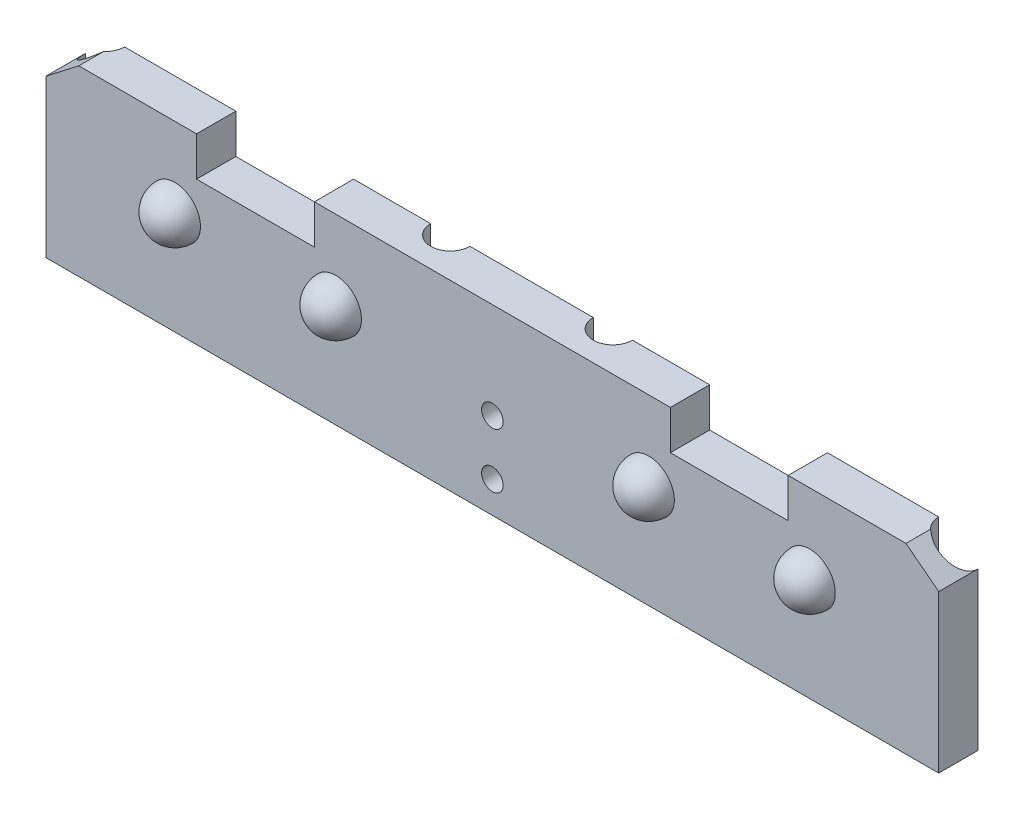
from build123d import *

# Parameters (mm, degrees)
SKETCH1_W                = 126.7
SKETCH1_H                = 14
BRACKETBASE_DEPTH        = 5
SKETCH2_R                = 1.375
MOUNTINGHOLES_DEPTH      = 1
MOUNTINGHOLES_DEPTH_BACK = 6
SKETCH5_W                = 126.7
SKETCH5_H                = 8.25
BASEEXTENSION_DEPTH      = 5
REVOLVE1_ANGLE           = 180
REVOLVE2_ANGLE           = 180
REVOLVE3_ANGLE           = 180
REVOLVE4_ANGLE           = 180
SKETCH9_W                = 15
SKETCH9_H                = 5
CUT_EXTRUDE2_DEPTH       = 4.25
CUT_EXTRUDE2_DEPTH_BACK  = 6
CUT_EXTRUDE3_DEPTH       = 4.25
CUT_EXTRUDE3_DEPTH_BACK  = 6
SKETCH11_R               = 2.5
CUT_EXTRUDE4_DEPTH       = 23.25
SKETCH12_R               = 2.5
CUT_EXTRUDE5_DEPTH       = 23.25
SKETCH13_W               = 6.5
SKETCH13_H               = 5
CUT_EXTRUDE6_DEPTH       = 1.0000001
CUT_EXTRUDE6_DEPTH_BACK  = 23.25
BOSS_EXTRUDE1_DEPTH      = 1


with BuildPart() as part:
    # Sketch1 → bracketBase (new body)
    with BuildSketch(Plane.XY):
        with Locations((63.35, 7)):
            Rectangle(SKETCH1_W, SKETCH1_H)
    extrude(amount=BRACKETBASE_DEPTH)

    # Sketch2 → mountingHoles (cut, two sides)
    with BuildSketch(Plane.XY.offset(5)) as mountingholes_sk:
        with Locations((63.35, 10)):
            Circle(SKETCH2_R)
        with Locations((63.35, 3)):
            Circle(SKETCH2_R)
        with Locations((123.7, 10)):
            Circle(SKETCH2_R)
        with Locations((123.7, 3)):
            Circle(SKETCH2_R)
        with Locations((3, 3)):
            Circle(SKETCH2_R)
        with Locations((3, 10)):
            Circle(SKETCH2_R)
    extrude(amount=MOUNTINGHOLES_DEPTH, mode=Mode.SUBTRACT)
    extrude(mountingholes_sk.sketch, amount=-MOUNTINGHOLES_DEPTH_BACK, mode=Mode.SUBTRACT)

    # Sketch5 → baseExtension (add)
    with BuildSketch(Plane.XY.offset(5)):
        with Locations((63.35, 18.125)):
            Rectangle(SKETCH5_W, SKETCH5_H)
    extrude(amount=-BASEEXTENSION_DEPTH)

    # Sketch4 → Revolve1 (revolve)
    with BuildSketch(Plane.XY.offset(5)):
        with BuildLine():
            Line((43.425, 9.00715266), (43.425, 15.50715266))
            ThreePointArc((43.425, 15.50715266), (40.175, 12.25715266), (43.425, 9.00715266))
        make_face()
    revolve(axis=Axis((43.425, 9.00715266, 5), (0, 1, 0)), revolution_arc=REVOLVE1_ANGLE)

    # Sketch6 → Revolve2 (revolve)
    with BuildSketch(Plane.XY.offset(5)):
        with BuildLine():
            Line((22.925, 9.00715266), (22.925, 15.50715266))
            ThreePointArc((22.925, 15.50715266), (26.175, 12.25715266), (22.925, 9.00715266))
        make_face()
    revolve(axis=Axis((22.925, 9.00715266, 5), (0, -1, 0)), revolution_arc=REVOLVE2_ANGLE)

    # Sketch7 → Revolve3 (revolve)
    with BuildSketch(Plane.XY.offset(5)):
        with BuildLine():
            Line((83.275, 9.00715266), (83.275, 15.50715266))
            ThreePointArc((83.275, 15.50715266), (86.525, 12.25715266), (83.275, 9.00715266))
        make_face()
    revolve(axis=Axis((83.275, 9.00715266, 5), (0, -1, 0)), revolution_arc=REVOLVE3_ANGLE)

    # Sketch8 → Revolve4 (revolve)
    with BuildSketch(Plane.XY.offset(5)):
        with BuildLine():
            Line((103.775, 9.00715266), (103.775, 15.50715266))
            ThreePointArc((103.775, 15.50715266), (100.525, 12.25715266), (103.775, 9.00715266))
        make_face()
    revolve(axis=Axis((103.775, 9.00715266, 5), (0, 1, 0)), revolution_arc=REVOLVE4_ANGLE)

    # Sketch9 → Cut-Extrude2 (cut, two sides)
    with BuildSketch(Plane.XY.offset(5)) as cut_extrude2_sk:
        with Locations((33.175, 19.75)):
            Rectangle(SKETCH9_W, SKETCH9_H)
        with Locations((93.525, 19.75)):
            Rectangle(SKETCH9_W, SKETCH9_H)
    extrude(amount=CUT_EXTRUDE2_DEPTH, mode=Mode.SUBTRACT)
    extrude(cut_extrude2_sk.sketch, amount=-CUT_EXTRUDE2_DEPTH_BACK, mode=Mode.SUBTRACT)

    # Sketch10 → Cut-Extrude3 (cut, two sides)
    with BuildSketch(Plane.XY.offset(5)) as cut_extrude3_sk:
        Polygon((116.025, 22.25), (126.7, 14), (126.7, 22.25), align=None)
        Polygon((0, 14), (0, 22.25), (10.675, 22.25), align=None)
    extrude(amount=CUT_EXTRUDE3_DEPTH, mode=Mode.SUBTRACT)
    extrude(cut_extrude3_sk.sketch, amount=-CUT_EXTRUDE3_DEPTH_BACK, mode=Mode.SUBTRACT)

    # Sketch11 → Cut-Extrude4 (cut, through all)
    with BuildSketch(Plane.XZ):
        with Locations((126.95, 1.155770847)):
            Circle(SKETCH11_R)
        with Locations((-0.25, 1.155770847)):
            Circle(SKETCH11_R)
    extrude(amount=-CUT_EXTRUDE4_DEPTH, mode=Mode.SUBTRACT)

    # Sketch12 → Cut-Extrude5 (cut, through all)
    with BuildSketch(Plane.XZ):
        with Locations((117.7, 0)):
            Circle(SKETCH12_R)
        with Locations((73.7, 0)):
            Circle(SKETCH12_R)
        with Locations((53, 0)):
            Circle(SKETCH12_R)
        with Locations((9, 0)):
            Circle(SKETCH12_R)
    extrude(amount=-CUT_EXTRUDE5_DEPTH, mode=Mode.SUBTRACT)

    # Sketch13 → Cut-Extrude6 (cut, two sides)
    with BuildSketch(Plane.XZ) as cut_extrude6_sk:
        with Locations((123.45, 2.5)):
            Rectangle(SKETCH13_W, SKETCH13_H)
        with Locations((3.25, 2.5)):
            Rectangle(SKETCH13_W, SKETCH13_H)
    extrude(amount=CUT_EXTRUDE6_DEPTH, mode=Mode.SUBTRACT)
    extrude(cut_extrude6_sk.sketch, amount=-CUT_EXTRUDE6_DEPTH_BACK, mode=Mode.SUBTRACT)

    # Sketch14 → Boss-Extrude1 (add)
    with BuildSketch(Plane.XZ):
        with BuildLine():
            Line((120.2, 0), (120.2, 5))
            Line((120.2, 5), (6.5, 5))
            Line((6.5, 5), (6.5, 0))
            ThreePointArc((6.5, 0), (9, 2.5), (11.5, 0))
            Line((11.5, 0), (50.5, 0))
            ThreePointArc((50.5, 0), (53, 2.5), (55.5, 0))
            Line((55.5, 0), (71.2, 0))
            ThreePointArc((71.2, 0), (73.7, 2.5), (76.2, 0))
            Line((76.2, 0), (115.2, 0))
            ThreePointArc((115.2, 0), (117.7, 2.5), (120.2, 0))
        make_face()
    extrude(amount=BOSS_EXTRUDE1_DEPTH)


solid = part.part
